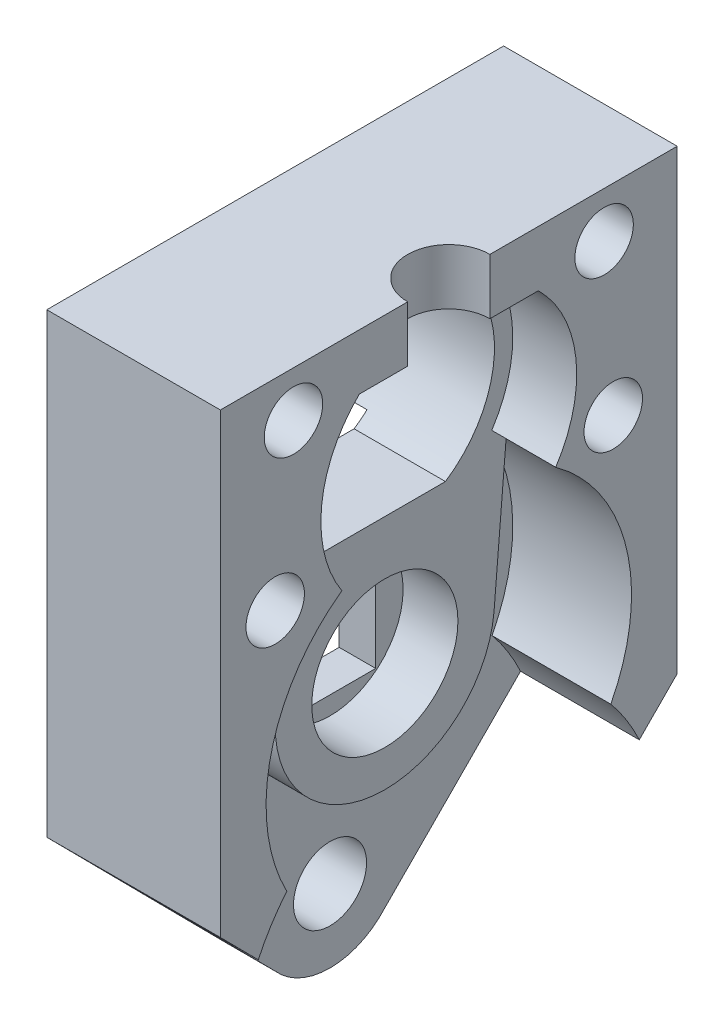
from build123d import *

# Parameters (mm, degrees)
SKETCH1_R           = 2
SKETCH1_W           = 5
SKETCH1_H           = 6
BOSS_EXTRUDE1_DEPTH = 9.5
CUT_EXTRUDE1_START  = 9.5
SKETCH1_6_R         = 2
SKETCH1_6_W         = 5
SKETCH1_6_H         = 6
CUT_EXTRUDE1_DEPTH  = 6.5
BOSS_EXTRUDE2_START = 3
SKETCH2_R           = 4
BOSS_EXTRUDE2_DEPTH = 3
BOSS_EXTRUDE3_START = 6
BOSS_EXTRUDE3_DEPTH = 3.5
CUT_EXTRUDE2_START  = 16.95
SKETCH3_R           = 2.25
CUT_EXTRUDE2_DEPTH  = 7
SKETCH5_R           = 1.6
CUT_EXTRUDE3_DEPTH  = 10
SKETCH6_W           = 17
SKETCH6_H           = 15
CUT_EXTRUDE4_DEPTH  = 1


with BuildPart() as part:
    # Sketch1 → Boss-Extrude1 (new body)
    with BuildSketch(Plane(origin=(0, 0, 0), x_dir=(0, 0, -1), z_dir=(1, 0, 0))):
        with BuildLine():
            Line((-12.5, -5), (-12.5, 20))
            Line((-12.5, 20), (12.5, 20))
            Line((12.5, 20), (12.5, -5))
            Line((12.5, -5), (3.003242416, -14.592070209))
            ThreePointArc((3.003242416, -14.592070209), (0, -15.95), (-3.003242416, -14.592070209))
            Line((-3.003242416, -14.592070209), (-12.5, -5))
        make_face()
        with Locations((0, -11.95)):
            Circle(SKETCH1_R, mode=Mode.SUBTRACT)
        with BuildLine():
            Line((-3.31662479, 6.95), (3.31662479, 6.95))
            ThreePointArc((3.31662479, 6.95), (6, 11.95), (3.31662479, 16.95))
            Line((3.31662479, 16.95), (-3.31662479, 16.95))
            ThreePointArc((-3.31662479, 16.95), (-6, 11.95), (-3.31662479, 6.95))
        make_face(mode=Mode.SUBTRACT)
        Rectangle(SKETCH1_W, SKETCH1_H, mode=Mode.SUBTRACT)
    extrude(amount=BOSS_EXTRUDE1_DEPTH)

    # Sketch1_6 → Cut-Extrude1 (cut)
    with BuildSketch(Plane(origin=(0, 0, 0), x_dir=(0, 0, -1), z_dir=(1, 0, 0)).offset(CUT_EXTRUDE1_START)):
        with BuildLine():
            ThreePointArc((-8.865865393, -4.625627615), (-9.724278097, -5.810910858), (-10.425207588, -7.09561572))
            Line((-10.425207588, -7.09561572), (-3.003242416, -14.592070209))
            ThreePointArc((-3.003242416, -14.592070209), (0, -15.95), (3.003242416, -14.592070209))
            Line((3.003242416, -14.592070209), (10.425207588, -7.09561572))
            ThreePointArc((10.425207588, -7.09561572), (9.724278097, -5.810910858), (8.865865393, -4.625627615))
            ThreePointArc((8.865865393, -4.625627615), (9.731180291, 2.303069722), (5.85199823, 8.108891213))
            ThreePointArc((5.85199823, 8.108891213), (0, 18.95), (-5.85199823, 8.108891213))
            ThreePointArc((-5.85199823, 8.108891213), (-9.731180291, 2.303069722), (-8.865865393, -4.625627615))
        make_face()
        with Locations((0, -11.95)):
            Circle(SKETCH1_6_R, mode=Mode.SUBTRACT)
        Rectangle(SKETCH1_6_W, SKETCH1_6_H, mode=Mode.SUBTRACT)
        with BuildLine():
            Line((3.31662479, 6.95), (-3.31662479, 6.95))
            ThreePointArc((-3.31662479, 6.95), (-6, 11.95), (-3.31662479, 16.95))
            Line((-3.31662479, 16.95), (3.31662479, 16.95))
            ThreePointArc((3.31662479, 16.95), (6, 11.95), (3.31662479, 6.95))
        make_face(mode=Mode.SUBTRACT)
    extrude(amount=-CUT_EXTRUDE1_DEPTH, mode=Mode.SUBTRACT)

    # Sketch2 → Boss-Extrude2 (add)
    with BuildSketch(Plane(origin=(0, 0, 0), x_dir=(0, 0, -1), z_dir=(1, 0, 0)).offset(BOSS_EXTRUDE2_START)):
        with BuildLine():
            Line((6.975447566, 11.364225941), (5.978955057, -0.50209205))
            ThreePointArc((5.978955057, -0.50209205), (0.004288423, -5.999998467), (-5.978231221, -0.510638298))
            Line((-5.978231221, -0.510638298), (-6.954880764, 11.156505474))
            ThreePointArc((-6.954880764, 11.156505474), (-0.104368082, 18.949221907), (6.975447566, 11.364225941))
        make_face()
        Circle(SKETCH2_R, mode=Mode.SUBTRACT)
        with BuildLine():
            Line((-3.31662479, 16.95), (3.31662479, 16.95))
            ThreePointArc((3.31662479, 16.95), (6, 11.95), (3.31662479, 6.95))
            Line((3.31662479, 6.95), (-3.31662479, 6.95))
            ThreePointArc((-3.31662479, 6.95), (-6, 11.95), (-3.31662479, 16.95))
        make_face(mode=Mode.SUBTRACT)
    extrude(amount=BOSS_EXTRUDE2_DEPTH)

    # Sketch4 → Boss-Extrude3 (add)
    with BuildSketch(Plane(origin=(0, 0, 0), x_dir=(0, 0, -1), z_dir=(1, 0, 0)).offset(BOSS_EXTRUDE3_START)):
        with BuildLine():
            Line((-4.898979486, 16.95), (4.898979486, 16.95))
            ThreePointArc((4.898979486, 16.95), (0, 18.95), (-4.898979486, 16.95))
        make_face()
    extrude(amount=BOSS_EXTRUDE3_DEPTH)

    # Sketch3 → Cut-Extrude2 (cut)
    with BuildSketch(Plane(origin=(0, 0, 0), x_dir=(1, 0, 0), z_dir=(0, 1, 0)).offset(CUT_EXTRUDE2_START)):
        with Locations((9.5, 0)):
            Circle(SKETCH3_R)
    extrude(amount=CUT_EXTRUDE2_DEPTH, mode=Mode.SUBTRACT)

    # Sketch5 → Cut-Extrude3 (cut)
    with BuildSketch(Plane(origin=(0, 0, 0), x_dir=(0, 0, -1), z_dir=(1, 0, 0))):
        with Locations((8.5, 17.5)):
            Circle(SKETCH5_R)
        with Locations((-8.5, 17.5)):
            Circle(SKETCH5_R)
        with Locations((9, 9)):
            Circle(SKETCH5_R)
        with Locations((-9.5, 9)):
            Circle(SKETCH5_R)
    extrude(amount=CUT_EXTRUDE3_DEPTH, mode=Mode.SUBTRACT)

    # Sketch6 → Cut-Extrude4 (cut)
    with BuildSketch(Plane(origin=(0, 0, 0), x_dir=(0, 0, -1), z_dir=(1, 0, 0))):
        Rectangle(SKETCH6_W, SKETCH6_H)
    extrude(amount=CUT_EXTRUDE4_DEPTH, mode=Mode.SUBTRACT)


solid = part.part
